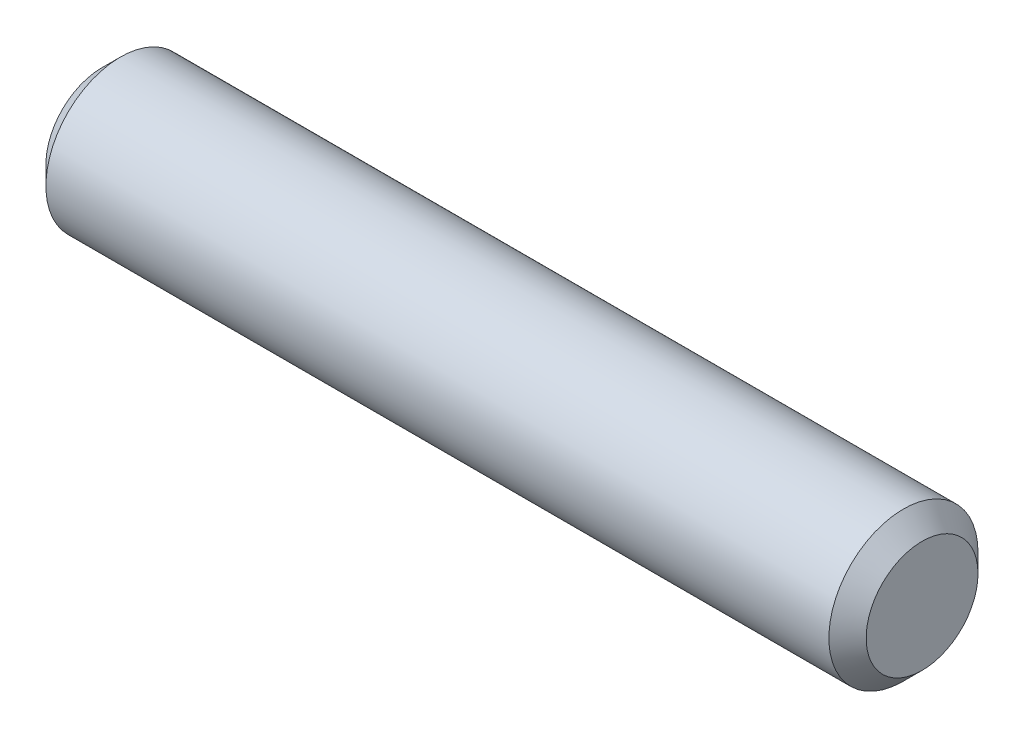
from build123d import *

# Parameters (mm, degrees)
SKETCH1_R           = 2
BOSS_EXTRUDE1_DEPTH = 22
CHAMFER1_SIZE       = 0.5


with BuildPart() as part:
    # Sketch1 → Boss-Extrude1 (new body)
    with BuildSketch(Plane(origin=(0, 0, 0), x_dir=(0, 0, -1), z_dir=(1, 0, 0))):
        Circle(SKETCH1_R)
    extrude(amount=BOSS_EXTRUDE1_DEPTH)

    # Chamfer1
    chamfer1_edges = [part.edges().sort_by_distance(p)[0] for p in [
        (0, 0, 2),
        (22, 0, 2),
    ]]
    chamfer(chamfer1_edges, length=CHAMFER1_SIZE)


solid = part.part
